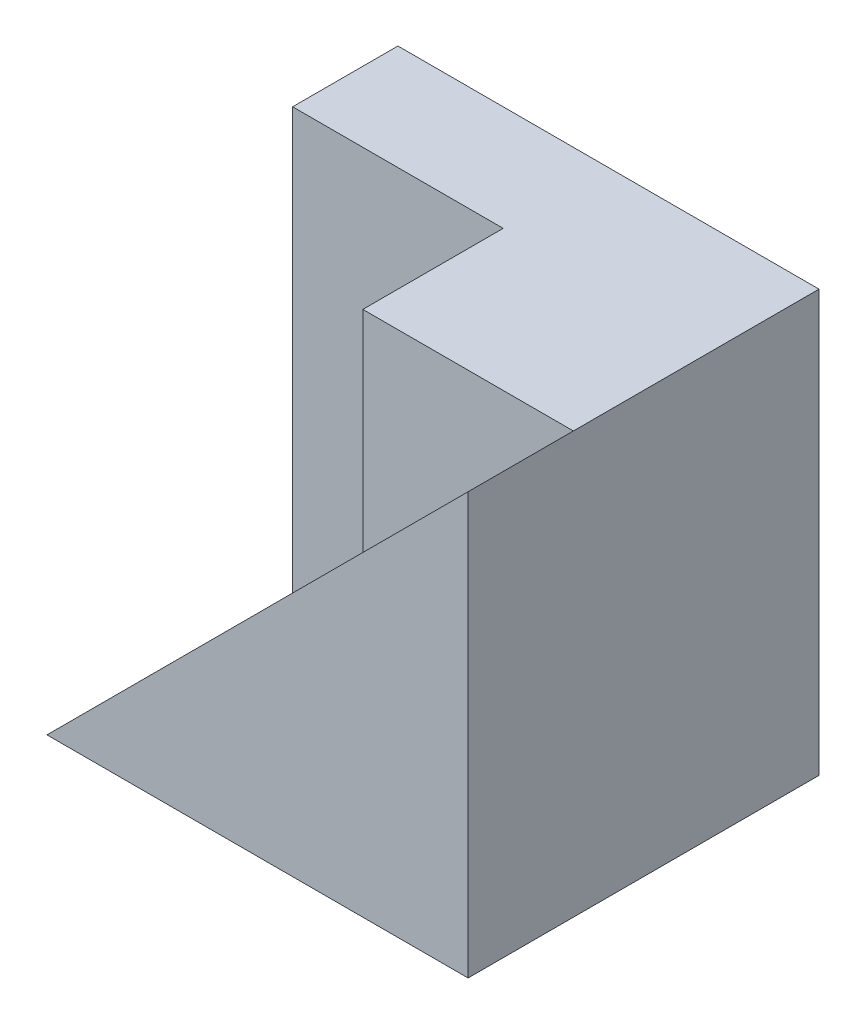
from build123d import *

# Parameters (mm, degrees)
SKETCH1_W           = 6
SKETCH1_H           = 5
BOSS_EXTRUDE1_DEPTH = 6
CUT_EXTRUDE1_DEPTH  = 3.5
SKETCH3_W           = 3
SKETCH3_H           = 2
BOSS_EXTRUDE2_DEPTH = 3


with BuildPart() as part:
    # Sketch1 → Boss-Extrude1 (new body)
    with BuildSketch(Plane(origin=(0, 0, 0), x_dir=(1, 0, 0), z_dir=(0, 1, 0))):
        Rectangle(SKETCH1_W, SKETCH1_H)
    extrude(amount=BOSS_EXTRUDE1_DEPTH)

    # Sketch2 → Cut-Extrude1 (cut)
    with BuildSketch(Plane.XY.offset(2.5)):
        Polygon((3, 6), (-3, 0), (-3, 6), align=None)
    extrude(amount=-CUT_EXTRUDE1_DEPTH, mode=Mode.SUBTRACT)

    # Sketch3 → Boss-Extrude2 (add)
    with BuildSketch(Plane(origin=(0, 6, 0), x_dir=(1, 0, 0), z_dir=(0, 1, 0))):
        with Locations((1.5, 0)):
            Rectangle(SKETCH3_W, SKETCH3_H)
    extrude(amount=-BOSS_EXTRUDE2_DEPTH)


solid = part.part
